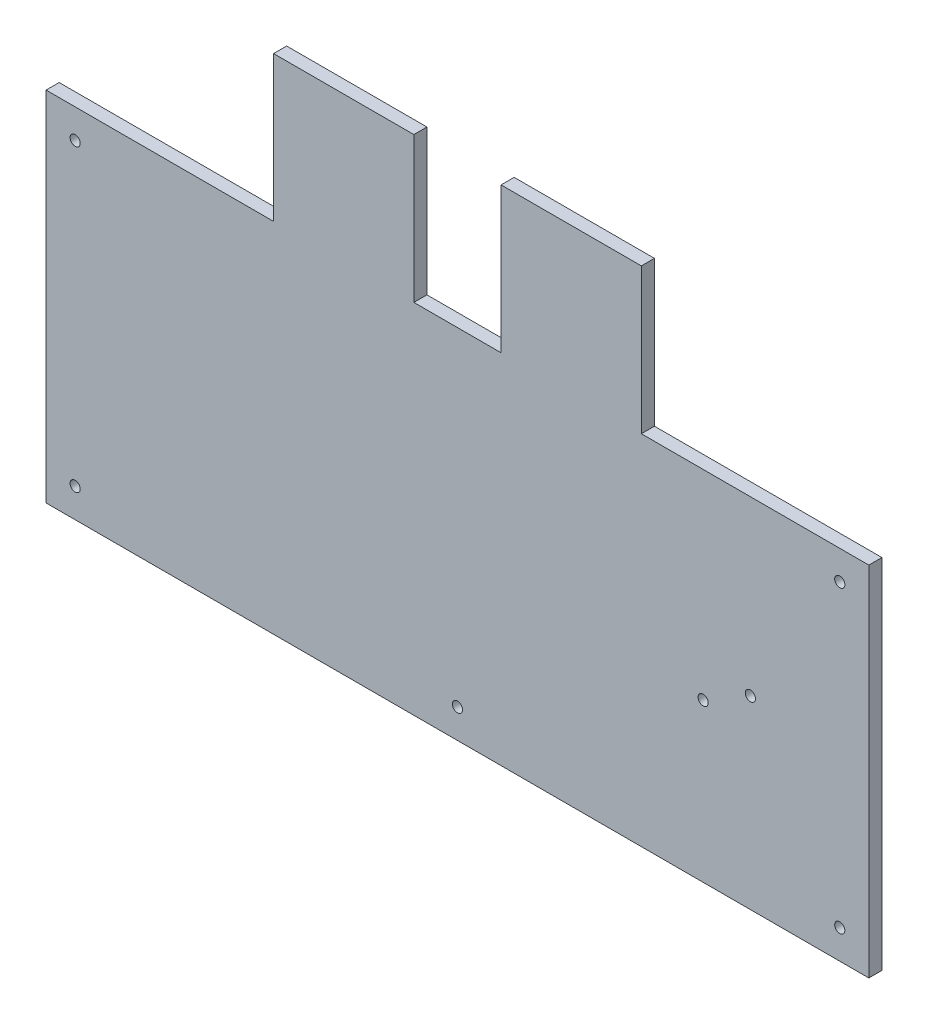
from build123d import *

# Parameters (mm, degrees)
SKETCH1_W           = 283
SKETCH1_H           = 173
SKETCH1_R           = 1.75
BOSS_EXTRUDE1_DEPTH = 4.5
CUT_EXTRUDE1_REACH  = 6.5
SKETCH2_W           = 78.25
SKETCH2_H           = 50
SKETCH2_W_2         = 30
SKETCH3_R           = 1.75
CUT_EXTRUDE2_DEPTH  = 10
CUT_EXTRUDE4_REACH  = 6.5
SKETCH5_R           = 1.75


with BuildPart() as part:
    # Sketch1 → Boss-Extrude1 (new body)
    with BuildSketch(Plane.XY):
        Rectangle(SKETCH1_W, SKETCH1_H)
        with Locations((-131.5, 76.5)):
            Circle(SKETCH1_R, mode=Mode.SUBTRACT)
        with Locations((-131.5, 76.5)):
            Circle(SKETCH1_R)
    extrude(amount=BOSS_EXTRUDE1_DEPTH)

    # Sketch2 → Cut-Extrude1 (cut, up to next)
    with BuildSketch(Plane.XY.offset(4.5), mode=Mode.PRIVATE) as cut_extrude1_sk1:
        with Locations((102.375, 61.5)):
            Rectangle(SKETCH2_W, SKETCH2_H)
    cut_extrude1_tool1 = extrude(cut_extrude1_sk1.sketch, amount=-CUT_EXTRUDE1_REACH, mode=Mode.PRIVATE) & part.part
    add(cut_extrude1_tool1.solids().sort_by_distance((102.375, 61.5, 4.5))[0], mode=Mode.SUBTRACT)
    # Sketch2 → Cut-Extrude1 (cut, up to next)
    with BuildSketch(Plane.XY.offset(4.5), mode=Mode.PRIVATE) as cut_extrude1_sk2:
        with Locations((-102.375, 61.5)):
            Rectangle(SKETCH2_W, SKETCH2_H)
    cut_extrude1_tool2 = extrude(cut_extrude1_sk2.sketch, amount=-CUT_EXTRUDE1_REACH, mode=Mode.PRIVATE) & part.part
    add(cut_extrude1_tool2.solids().sort_by_distance((-102.375, 61.5, 4.5))[0], mode=Mode.SUBTRACT)
    # Sketch2 → Cut-Extrude1 (cut, up to next)
    with BuildSketch(Plane.XY.offset(4.5), mode=Mode.PRIVATE) as cut_extrude1_sk3:
        with Locations((0, 61.5)):
            Rectangle(SKETCH2_W_2, SKETCH2_H)
    cut_extrude1_tool3 = extrude(cut_extrude1_sk3.sketch, amount=-CUT_EXTRUDE1_REACH, mode=Mode.PRIVATE) & part.part
    add(cut_extrude1_tool3.solids().sort_by_distance((0, 61.5, 4.5))[0], mode=Mode.SUBTRACT)

    # Sketch3 → Cut-Extrude2 (cut)
    with BuildSketch(Plane.XY.offset(4.5)):
        with Locations((-131.5, -76.5)):
            Circle(SKETCH3_R)
        with Locations((131.5, -76.5)):
            Circle(SKETCH3_R)
        with Locations((131.5, 26.5)):
            Circle(SKETCH3_R)
        with Locations((-131.5, 26.5)):
            Circle(SKETCH3_R)
        with Locations((0, -76.5)):
            Circle(SKETCH3_R)
    extrude(amount=-CUT_EXTRUDE2_DEPTH, mode=Mode.SUBTRACT)

    # Sketch5 → Cut-Extrude4 (cut, up to next)
    with BuildSketch(Plane.XY.offset(4.5), mode=Mode.PRIVATE) as cut_extrude4_sk1:
        with Locations((84.512023679, -32.2)):
            Circle(SKETCH5_R)
    cut_extrude4_tool1 = extrude(cut_extrude4_sk1.sketch, amount=-CUT_EXTRUDE4_REACH, mode=Mode.PRIVATE) & part.part
    add(cut_extrude4_tool1.solids().sort_by_distance((84.512024, -32.2, 4.5))[0], mode=Mode.SUBTRACT)
    # Sketch5 → Cut-Extrude4 (cut, up to next)
    with BuildSketch(Plane.XY.offset(4.5), mode=Mode.PRIVATE) as cut_extrude4_sk2:
        with Locations((100.75, -22.825)):
            Circle(SKETCH5_R)
    cut_extrude4_tool2 = extrude(cut_extrude4_sk2.sketch, amount=-CUT_EXTRUDE4_REACH, mode=Mode.PRIVATE) & part.part
    add(cut_extrude4_tool2.solids().sort_by_distance((100.75, -22.825, 4.5))[0], mode=Mode.SUBTRACT)


solid = part.part
